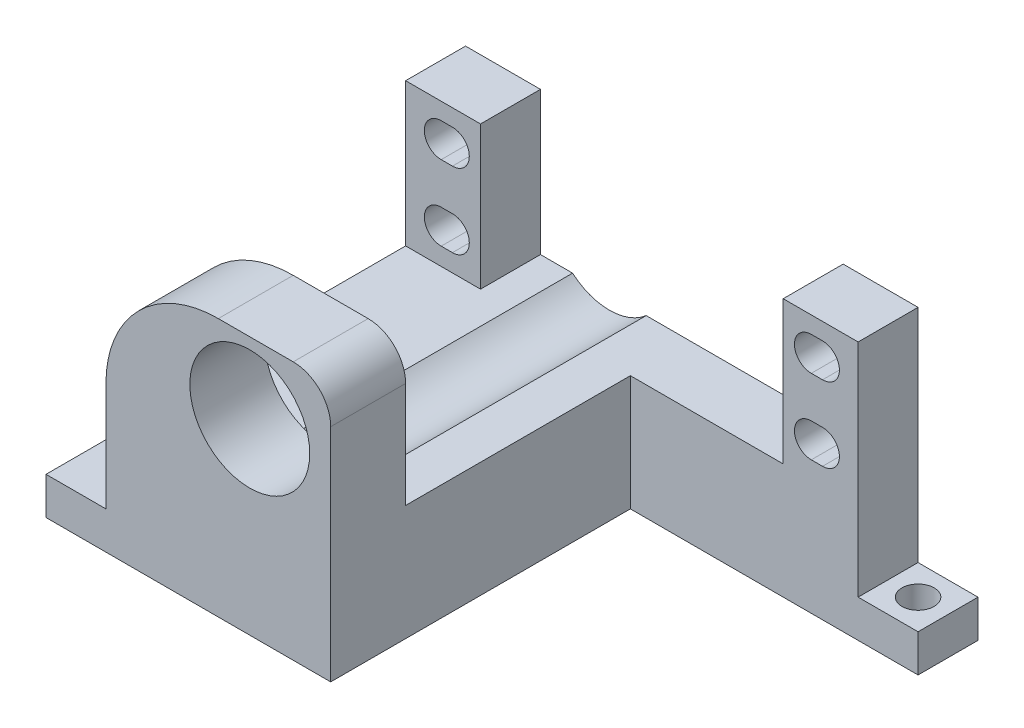
from build123d import *

# Parameters (mm, degrees)
BOSS_EXTRUDE1_DEPTH = 8
SKETCH7_W           = 30
SKETCH7_H           = 15.4
BOSS_EXTRUDE2_DEPTH = 40
SKETCH8_W           = 30
SKETCH8_H           = 10
BOSS_EXTRUDE3_DEPTH = 19.1
SKETCH9_R           = 8
CUT_EXTRUDE1_DEPTH  = 10
FILLET2_R           = 15
FILLET3_R           = 5
SKETCH11_R          = 7.5
CUT_EXTRUDE2_DEPTH  = 38
SKETCH14_W          = 8
SKETCH14_H          = 5
BOSS_EXTRUDE5_DEPTH = 8
SKETCH15_W          = 48
SKETCH15_H          = 5
BOSS_EXTRUDE6_DEPTH = 8
SKETCH16_R          = 2.15
CUT_EXTRUDE4_DEPTH  = 5


with BuildPart() as part:
    # Sketch6 → Boss-Extrude1 (new body)
    with BuildSketch(Plane.XY):
        Polygon((-16.08404704, 11.385723939), (-16.08404704, -7.714276061), (24.31595296, -7.714276061), (24.31595296, 11.385723939), (34.31595296, 11.385723939), (34.31595296, -23.114276061), (-26.08404704, -23.114276061), (-26.08404704, 11.385723939), align=None)
        with BuildLine():
            Line((-19.83404704, 4.635723939), (-21.33404704, 4.635723939))
            ThreePointArc((-21.33404704, 4.635723939), (-23.58404704, 6.885723939), (-21.33404704, 9.135723939))
            Line((-21.33404704, 9.135723939), (-19.83404704, 9.135723939))
            ThreePointArc((-19.83404704, 9.135723939), (-17.58404704, 6.885723939), (-19.83404704, 4.635723939))
        make_face(mode=Mode.SUBTRACT)
        with BuildLine():
            Line((-19.83404704, -5.364276061), (-21.33404704, -5.364276061))
            ThreePointArc((-21.33404704, -5.364276061), (-23.58404704, -3.114276061), (-21.33404704, -0.864276061))
            Line((-21.33404704, -0.864276061), (-19.83404704, -0.864276061))
            ThreePointArc((-19.83404704, -0.864276061), (-17.58404704, -3.114276061), (-19.83404704, -5.364276061))
        make_face(mode=Mode.SUBTRACT)
        with BuildLine():
            Line((28.06595296, -5.364276061), (29.56595296, -5.364276061))
            ThreePointArc((29.56595296, -5.364276061), (31.81595296, -3.114276061), (29.56595296, -0.864276061))
            Line((29.56595296, -0.864276061), (28.06595296, -0.864276061))
            ThreePointArc((28.06595296, -0.864276061), (25.81595296, -3.114276061), (28.06595296, -5.364276061))
        make_face(mode=Mode.SUBTRACT)
        with BuildLine():
            Line((28.06595296, 4.635723939), (29.56595296, 4.635723939))
            ThreePointArc((29.56595296, 4.635723939), (31.81595296, 6.885723939), (29.56595296, 9.135723939))
            Line((29.56595296, 9.135723939), (28.06595296, 9.135723939))
            ThreePointArc((28.06595296, 9.135723939), (25.81595296, 6.885723939), (28.06595296, 4.635723939))
        make_face(mode=Mode.SUBTRACT)
    extrude(amount=BOSS_EXTRUDE1_DEPTH)

    # Sketch7 → Boss-Extrude2 (add)
    with BuildSketch(Plane.XY.offset(8)):
        with Locations((-11.08404704, -15.414276061)):
            Rectangle(SKETCH7_W, SKETCH7_H)
    extrude(amount=BOSS_EXTRUDE2_DEPTH)

    # Sketch8 → Boss-Extrude3 (add)
    with BuildSketch(Plane(origin=(0, -7.714276061, 0), x_dir=(1, 0, 0), z_dir=(0, 1, 0))):
        with Locations((-11.08404704, -43)):
            Rectangle(SKETCH8_W, SKETCH8_H)
    extrude(amount=BOSS_EXTRUDE3_DEPTH)

    # Sketch9 → Cut-Extrude1 (cut)
    with BuildSketch(Plane.XY.offset(48)):
        with Locations((-6.88404704, 1.885723939)):
            Circle(SKETCH9_R)
    extrude(amount=-CUT_EXTRUDE1_DEPTH, mode=Mode.SUBTRACT)

    # Fillet2
    fillet2_edges = [part.edges().sort_by_distance(p)[0] for p in [
        (-26.08404704, 11.385723939, 43),
    ]]
    fillet(fillet2_edges, radius=FILLET2_R)

    # Fillet3
    fillet3_edges = [part.edges().sort_by_distance(p)[0] for p in [
        (3.91595296, 11.385723939, 43),
    ]]
    fillet(fillet3_edges, radius=FILLET3_R)

    # Sketch11 → Cut-Extrude2 (cut)
    with BuildSketch(Plane(origin=(0, 0, 0), x_dir=(-1, 0, 0), z_dir=(0, 0, -1))):
        with Locations((6.88404704, -2.044839291)):
            Circle(SKETCH11_R)
    extrude(amount=-CUT_EXTRUDE2_DEPTH, mode=Mode.SUBTRACT)

    # Sketch14 → Boss-Extrude5 (add)
    with BuildSketch(Plane(origin=(34.31595296, 0, 0), x_dir=(0, 0, -1), z_dir=(1, 0, 0))):
        with Locations((-4, -20.614276061)):
            Rectangle(SKETCH14_W, SKETCH14_H)
    extrude(amount=BOSS_EXTRUDE5_DEPTH)

    # Sketch15 → Boss-Extrude6 (add)
    with BuildSketch(Plane.ZY.offset(26.08404704)):
        with Locations((24, -20.614276061)):
            Rectangle(SKETCH15_W, SKETCH15_H)
    extrude(amount=BOSS_EXTRUDE6_DEPTH)

    # Sketch16 → Cut-Extrude4 (cut)
    with BuildSketch(Plane(origin=(0, -18.114276061, 0), x_dir=(1, 0, 0), z_dir=(0, 1, 0))):
        with Locations((-30.08404704, -11)):
            Circle(SKETCH16_R)
        with Locations((-30.08404704, -36)):
            Circle(SKETCH16_R)
        with Locations((38.31595296, -4)):
            Circle(SKETCH16_R)
    extrude(amount=-CUT_EXTRUDE4_DEPTH, mode=Mode.SUBTRACT)


solid = part.part
